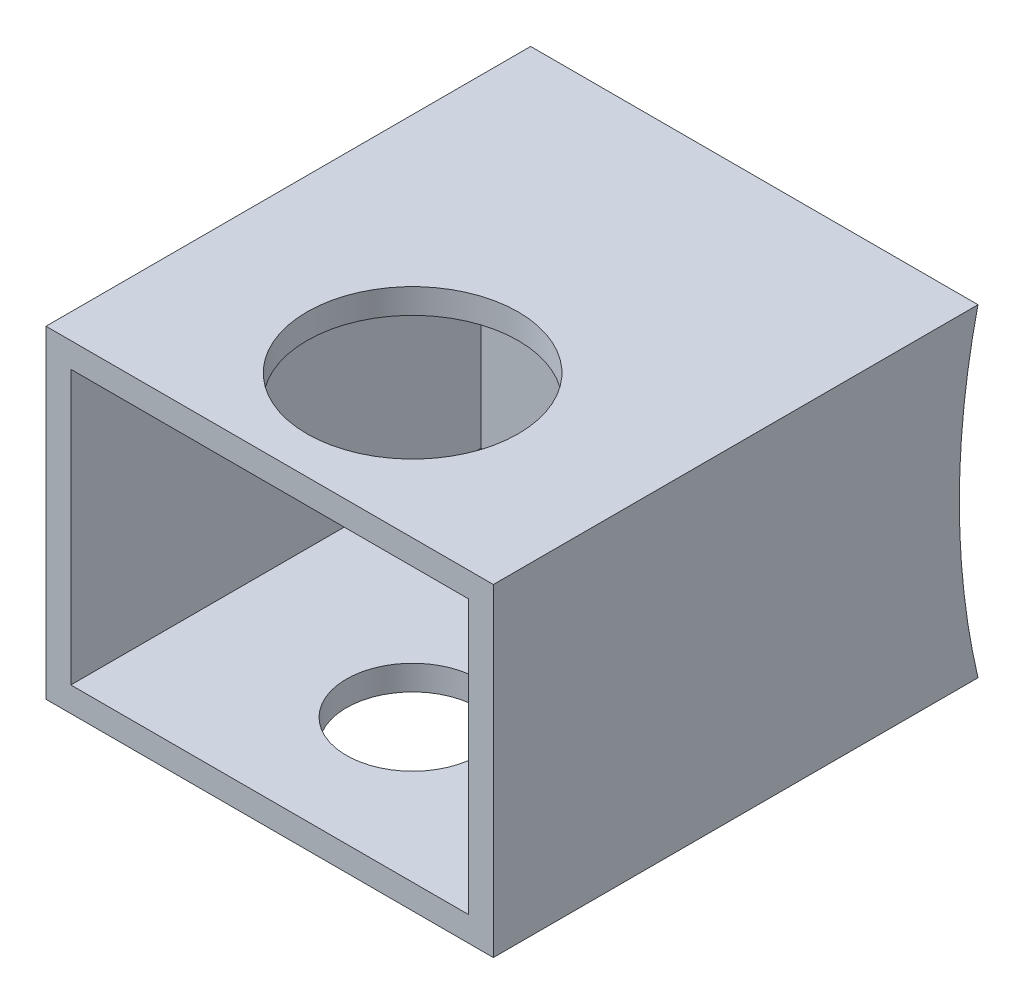
from build123d import *

# Parameters (mm, degrees)
SKETCH1_W                 = 9.144
SKETCH1_H                 = 6.604
BOSS_EXTRUDE1_DEPTH       = 9.906
SKETCH4_W                 = 8.128
SKETCH4_H                 = 5.588
CUT_EXTRUDE1_DEPTH        = 8.382
CUT_EXTRUDE2_DEPTH        = 10.144
CUT_EXTRUDE4_REACH        = 8.604
SKETCH11_R                = 2.159
F_6_32_TAPPED_HOLE4_D     = 2.7051
F_6_32_TAPPED_HOLE4_DEPTH = 0.508


with BuildPart() as part:
    # Sketch1 → Boss-Extrude1 (new body)
    with BuildSketch(Plane.XY):
        with Locations((-3.267592039, 1.740807143)):
            Rectangle(SKETCH1_W, SKETCH1_H)
    extrude(amount=BOSS_EXTRUDE1_DEPTH)

    # Sketch4 → Cut-Extrude1 (cut)
    with BuildSketch(Plane.XY.offset(9.906)):
        with Locations((-3.267592039, 1.740807143)):
            Rectangle(SKETCH4_W, SKETCH4_H)
    extrude(amount=-CUT_EXTRUDE1_DEPTH, mode=Mode.SUBTRACT)

    # Sketch8 → Cut-Extrude2 (cut, through all)
    with BuildSketch(Plane.ZY.offset(7.839592039)):
        with BuildLine():
            Line((0, 5.042807143), (0, -1.561192857))
            ThreePointArc((0, -1.561192857), (0.381572084, 1.740807143), (0, 5.042807143))
        make_face()
    extrude(amount=-CUT_EXTRUDE2_DEPTH, mode=Mode.SUBTRACT)

    # Sketch11 → Cut-Extrude4 (cut, up to next)
    with BuildSketch(Plane(origin=(0, 5.042807143, 0), x_dir=(1, 0, 0), z_dir=(0, 1, 0)), mode=Mode.PRIVATE) as cut_extrude4_sk1:
        with Locations((-3.267592039, -6.985)):
            Circle(SKETCH11_R)
    cut_extrude4_tool1 = extrude(cut_extrude4_sk1.sketch, amount=-CUT_EXTRUDE4_REACH, mode=Mode.PRIVATE) & part.part
    add(cut_extrude4_tool1.solids().sort_by_distance((-3.267592, 5.042807, 6.985))[0], mode=Mode.SUBTRACT)

    # #6-32 Tapped Hole4
    with Locations(Plane(origin=(0, -1.561192857, 0), x_dir=(-1, 0, 0), z_dir=(0, -1, 0))):
        with Locations((3.267592039, -6.985)):
            Hole(F_6_32_TAPPED_HOLE4_D / 2, depth=F_6_32_TAPPED_HOLE4_DEPTH)


solid = part.part
